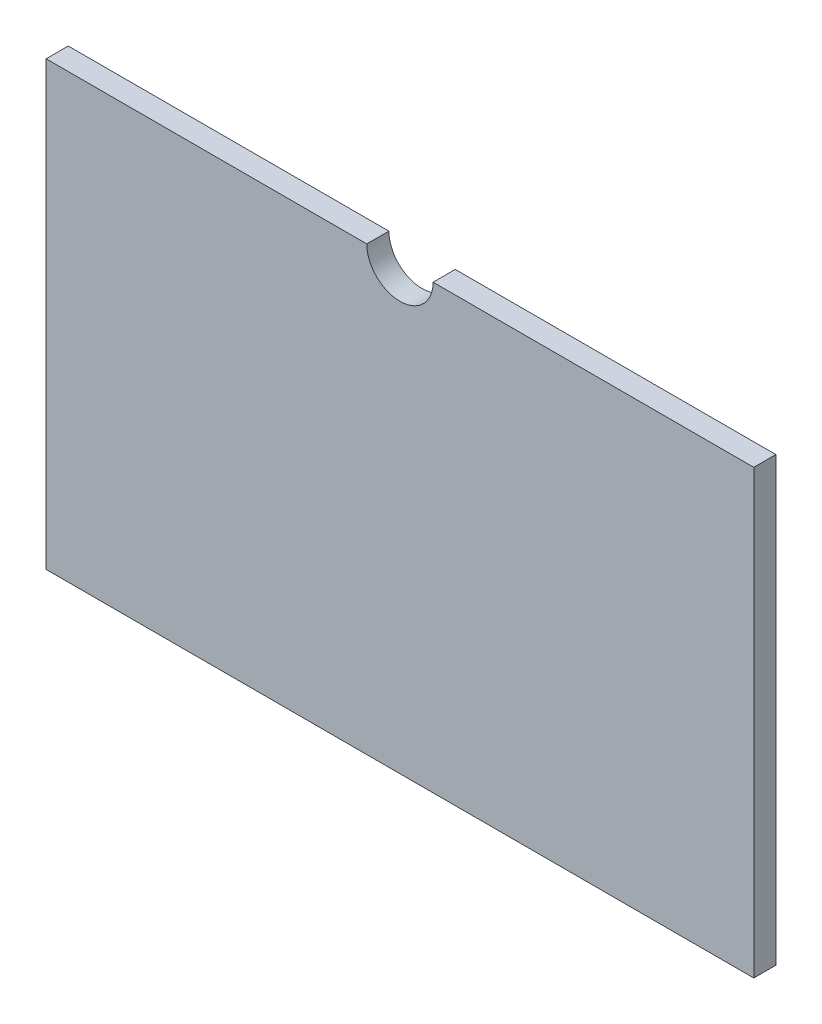
from build123d import *

# Parameters (mm, degrees)
BOTTOM_CENTER_CASING_DEPTH = 10


with BuildPart() as part:
    # Sketch1 → Bottom Center Casing (new body)
    with BuildSketch(Plane.XY):
        with BuildLine():
            Line((-160, 100), (-15, 100))
            ThreePointArc((-15, 100), (0, 85), (15, 100))
            Line((15, 100), (160, 100))
            Line((160, 100), (160, -100))
            Line((160, -100), (-160, -100))
            Line((-160, -100), (-160, 100))
        make_face()
    extrude(amount=BOTTOM_CENTER_CASING_DEPTH)


solid = part.part
